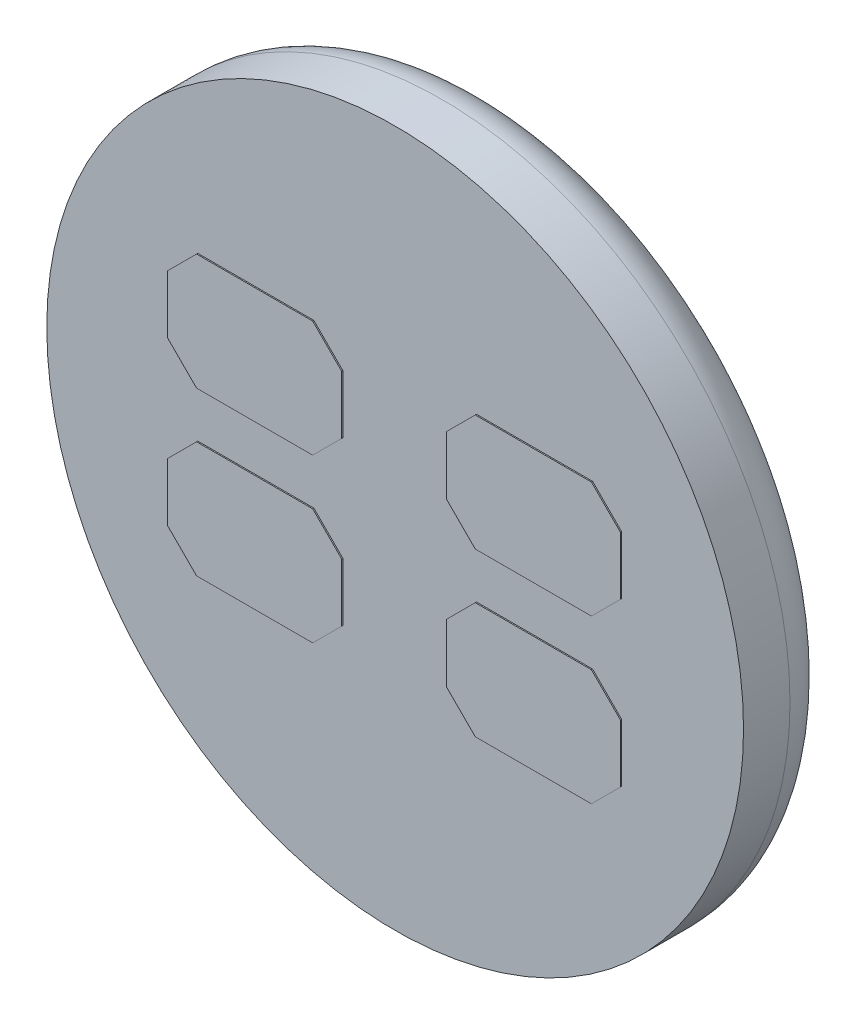
from build123d import *

# Parameters (mm, degrees)
SKETCH_1_R      = 3
EXTRUDE_1_DEPTH = 0.8
SKETCH_2_R      = 2.2
SKETCH_2_R_2    = 1.7
SKETCH_2_R_3    = 1.55
SKETCH_2_R_4    = 1.05
SKETCH_2_R_5    = 0.85
SKETCH_2_R_6    = 0.45
SKETCH_2_R_7    = 0.3
EXTRUDE_2_DEPTH = 0.01
EXTRUDE_3_DEPTH = 0.01
FILLET_2_R      = 0.4


with BuildPart() as part:
    # 草图1 → 凸台-拉伸1 (new body)
    with BuildSketch(Plane.XY):
        Circle(SKETCH_1_R)
    extrude(amount=EXTRUDE_1_DEPTH)

    # 草图2 → 凸台-拉伸2 (add)
    with BuildSketch(Plane(origin=(0, 0, 0), x_dir=(-1, 0, 0), z_dir=(0, 0, -1))):
        with Locations(Location((0, 0, 0), (0, 0, 180))):  # turned: the seam where the file's is
            Circle(SKETCH_2_R)
        Circle(SKETCH_2_R_2, mode=Mode.SUBTRACT)
        with Locations(Location((0, 0, 0), (0, 0, 180))):  # turned: the seam where the file's is
            Circle(SKETCH_2_R_3)
        Circle(SKETCH_2_R_4, mode=Mode.SUBTRACT)
        with Locations(Location((0, 0, 0), (0, 0, 180))):  # turned: the seam where the file's is
            Circle(SKETCH_2_R_5)
        Circle(SKETCH_2_R_6, mode=Mode.SUBTRACT)
        with Locations(Location((0, 0, 0), (0, 0, 180))):  # turned: the seam where the file's is
            Circle(SKETCH_2_R_7)
    extrude(amount=EXTRUDE_2_DEPTH)

    # 草图3 → 凸台-拉伸3 (add)
    with BuildSketch(Plane.XY.offset(0.8)):
        Polygon((-0.45, 0.95), (-0.7, 1.2), (-1.7, 1.2), (-1.95, 0.95), (-1.95, 0.45), (-1.7, 0.2), (-0.7, 0.2), (-0.45, 0.45), align=None)
        Polygon((0.45, 0.95), (0.45, 0.45), (0.7, 0.2), (1.7, 0.2), (1.95, 0.45), (1.95, 0.95), (1.7, 1.2), (0.7, 1.2), align=None)
        Polygon((0.45, -0.95), (0.7, -1.2), (1.7, -1.2), (1.95, -0.95), (1.95, -0.45), (1.7, -0.2), (0.7, -0.2), (0.45, -0.45), align=None)
        Polygon((-0.45, -0.95), (-0.45, -0.45), (-0.7, -0.2), (-1.7, -0.2), (-1.95, -0.45), (-1.95, -0.95), (-1.7, -1.2), (-0.7, -1.2), align=None)
    extrude(amount=EXTRUDE_3_DEPTH)

    # 圆角2
    fillet_2_edges = [part.edges().sort_by_distance(p)[0] for p in [
        (-3, 0, 0),
    ]]
    fillet(fillet_2_edges, radius=FILLET_2_R)


solid = part.part
